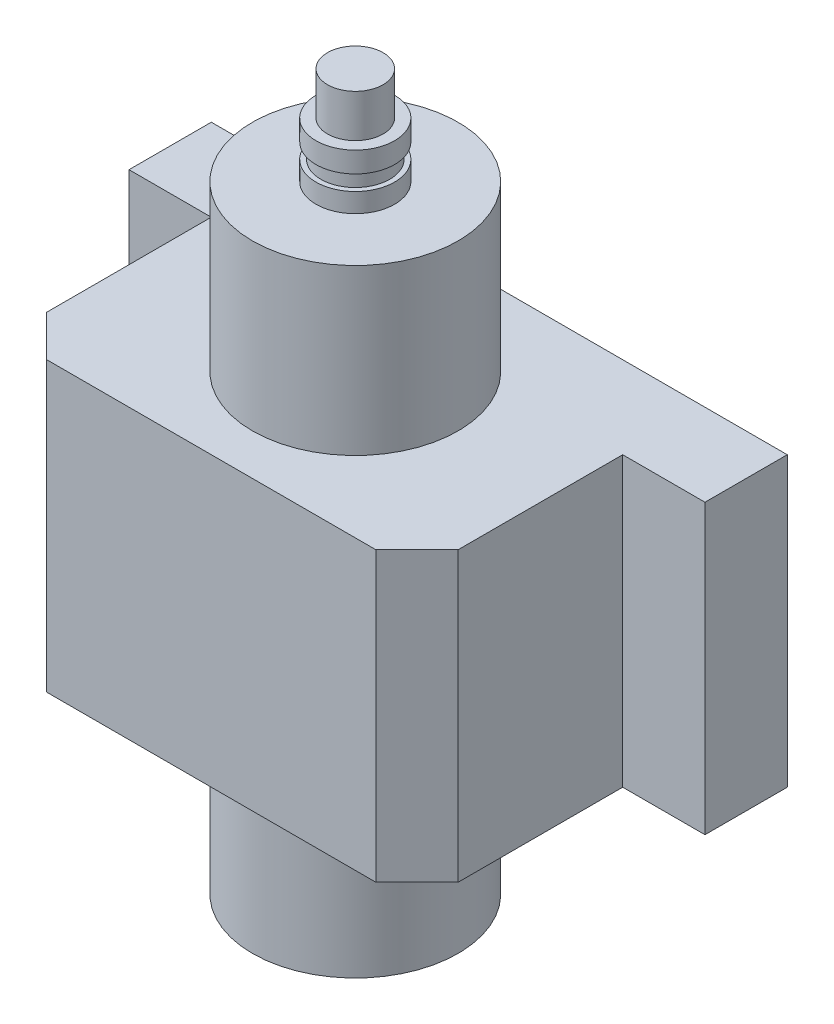
from build123d import *

# Parameters (mm, degrees)
SKETCH1_R           = 25
BOSS_EXTRUDE1_DEPTH = 70
SKETCH3_R           = 25
BOSS_EXTRUDE2_DEPTH = 75
CHAMFER1_SIZE       = 10


with BuildPart() as part:
    # Sketch1 → Boss-Extrude1 (new body)
    with BuildSketch(Plane(origin=(0, 0, 0), x_dir=(1, 0, 0), z_dir=(0, 1, 0))):
        Polygon((70, 0), (-70, 0), (-70, -20), (-50, -20), (-50, -70), (50, -70), (50, -20), (70, -20), align=None)
        with Locations((0, -35)):
            Circle(SKETCH1_R, mode=Mode.SUBTRACT)
    extrude(amount=BOSS_EXTRUDE1_DEPTH)

    # Sketch3 → Boss-Extrude2 (add, symmetric)
    with BuildSketch(Plane(origin=(0, 35, 0), x_dir=(1, 0, 0), z_dir=(0, 1, 0))):
        with Locations((0, -35)):
            Circle(SKETCH3_R)
    extrude(amount=BOSS_EXTRUDE2_DEPTH, both=True)

    # Sketch4 → Revolve1 (revolve)
    with BuildSketch(Plane.XY.offset(35)):
        Polygon((-9.564011188, 110), (0, 110), (0, 133.766089862), (-6.754803398, 133.766089862), (-6.754803398, 123.383600129), (-9.564011188, 123.383600129), (-9.564011188, 118.357377814), (-8.389537285, 118.357377814), (-8.389537285, 114.668590284), (-9.564011188, 114.668590284), align=None)
        Polygon((0, -40), (-9.564011188, -40), (-9.564011188, -50.700633695), (-4.891534663, -50.700633695), (-4.891534663, -52.417938892), (0, -52.417938892), align=None)
    revolve(axis=Axis((0, -40, 35), (0, -1, 0)))

    # Chamfer1
    chamfer1_edges = [part.edges().sort_by_distance(p)[0] for p in [
        (50, 35, 70),
        (-50, 35, 70),
    ]]
    chamfer(chamfer1_edges, length=CHAMFER1_SIZE)


solid = part.part
